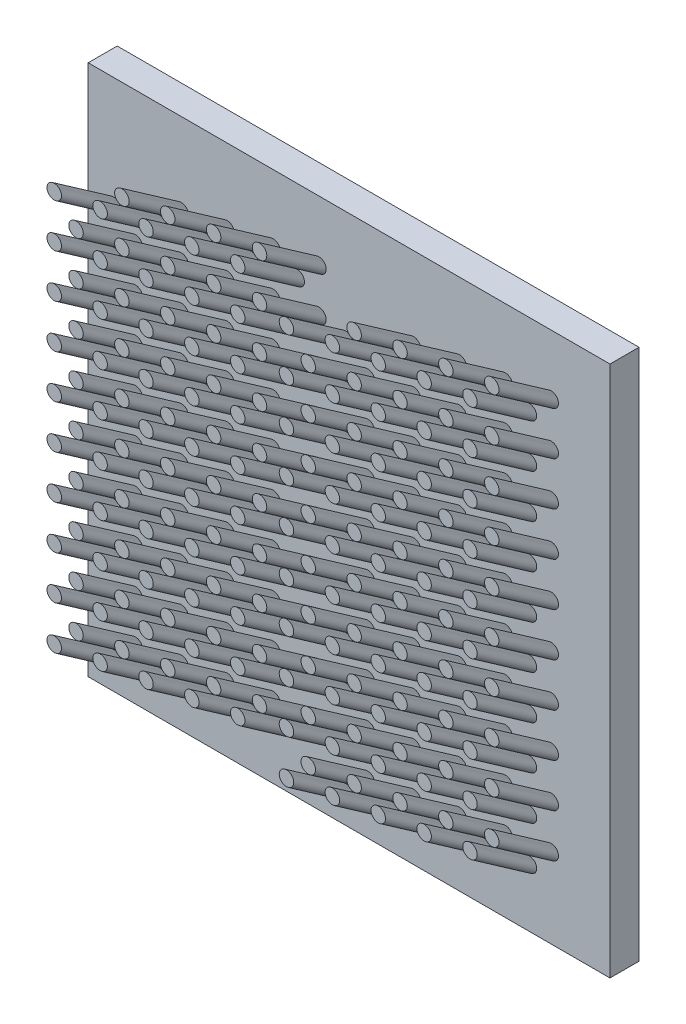
from build123d import *

# Parameters (mm, degrees)
SKETCH1_R       = 0.125
EXTRUDE1_DEPTH  = 1.25
LPATTERN2_COUNT = 2
LPATTERN2_PITCH = 4
EXTRUDE2_START  = -0.5
SKETCH5_W       = 8.986878449
SKETCH5_H       = 9.157970872
EXTRUDE2_DEPTH  = 0.5


with BuildPart() as part:
    # Sketch1 → Extrude1 (new body, along a direction that is not the sketch's normal)
    with BuildSketch(Plane.XY):
        with Locations((3.16060269, 0.500590288)):
            Circle(SKETCH1_R)
        with Locations((3.16060269, 1.250590288)):
            Circle(SKETCH1_R)
        with Locations((3.16060269, 2.000590288)):
            Circle(SKETCH1_R)
        with Locations((3.16060269, 2.750590288)):
            Circle(SKETCH1_R)
        with Locations((3.16060269, 3.500590288)):
            Circle(SKETCH1_R)
        with Locations((3.16060269, 4.250590288)):
            Circle(SKETCH1_R)
        with Locations((3.16060269, 5.000590288)):
            Circle(SKETCH1_R)
        with Locations((3.16060269, 5.750590288)):
            Circle(SKETCH1_R)
        with Locations((3.16060269, 6.500590288)):
            Circle(SKETCH1_R)
        with Locations((3.16060269, 7.250590288)):
            Circle(SKETCH1_R)
        with Locations((3.535546061, 0.875533659)):
            Circle(SKETCH1_R)
        with Locations((3.535546061, 1.625533659)):
            Circle(SKETCH1_R)
        with Locations((3.535546061, 2.375533659)):
            Circle(SKETCH1_R)
        with Locations((3.535546061, 3.125533659)):
            Circle(SKETCH1_R)
        with Locations((3.535546061, 3.875533659)):
            Circle(SKETCH1_R)
        with Locations((3.535546061, 4.625533659)):
            Circle(SKETCH1_R)
        with Locations((3.535546061, 5.375533659)):
            Circle(SKETCH1_R)
        with Locations((3.535546061, 6.125533659)):
            Circle(SKETCH1_R)
        with Locations((3.535546061, 6.875533659)):
            Circle(SKETCH1_R)
        with Locations((3.950753362, 0.62573786)):
            Circle(SKETCH1_R)
        with Locations((3.950753362, 1.37573786)):
            Circle(SKETCH1_R)
        with Locations((3.950753362, 2.12573786)):
            Circle(SKETCH1_R)
        with Locations((3.950753362, 2.87573786)):
            Circle(SKETCH1_R)
        with Locations((3.950753362, 3.62573786)):
            Circle(SKETCH1_R)
        with Locations((3.950753362, 4.37573786)):
            Circle(SKETCH1_R)
        with Locations((3.950753362, 5.12573786)):
            Circle(SKETCH1_R)
        with Locations((3.950753362, 5.87573786)):
            Circle(SKETCH1_R)
        with Locations((3.950753362, 6.62573786)):
            Circle(SKETCH1_R)
        with Locations((3.950753362, 7.37573786)):
            Circle(SKETCH1_R)
        with Locations((4.325696733, 1.000681231)):
            Circle(SKETCH1_R)
        with Locations((4.325696733, 1.750681231)):
            Circle(SKETCH1_R)
        with Locations((4.325696733, 2.500681231)):
            Circle(SKETCH1_R)
        with Locations((4.325696733, 3.250681231)):
            Circle(SKETCH1_R)
        with Locations((4.325696733, 4.000681231)):
            Circle(SKETCH1_R)
        with Locations((4.325696733, 4.750681231)):
            Circle(SKETCH1_R)
        with Locations((4.325696733, 5.500681231)):
            Circle(SKETCH1_R)
        with Locations((4.325696733, 6.250681231)):
            Circle(SKETCH1_R)
        with Locations((4.325696733, 7.000681231)):
            Circle(SKETCH1_R)
        with Locations((4.325696733, 7.750681231)):
            Circle(SKETCH1_R)
        with Locations((4.740904035, 0.750885432)):
            Circle(SKETCH1_R)
        with Locations((4.740904035, 1.500885432)):
            Circle(SKETCH1_R)
        with Locations((4.740904035, 2.250885432)):
            Circle(SKETCH1_R)
        with Locations((4.740904035, 3.000885432)):
            Circle(SKETCH1_R)
        with Locations((4.740904035, 3.750885432)):
            Circle(SKETCH1_R)
        with Locations((4.740904035, 4.500885432)):
            Circle(SKETCH1_R)
        with Locations((4.740904035, 5.250885432)):
            Circle(SKETCH1_R)
        with Locations((4.740904035, 6.000885432)):
            Circle(SKETCH1_R)
        with Locations((4.740904035, 6.750885432)):
            Circle(SKETCH1_R)
        with Locations((4.740904035, 7.500885432)):
            Circle(SKETCH1_R)
        with Locations((5.115847406, 1.125828803)):
            Circle(SKETCH1_R)
        with Locations((5.115847406, 1.875828803)):
            Circle(SKETCH1_R)
        with Locations((5.115847406, 2.625828803)):
            Circle(SKETCH1_R)
        with Locations((5.115847406, 3.375828803)):
            Circle(SKETCH1_R)
        with Locations((5.115847406, 4.125828803)):
            Circle(SKETCH1_R)
        with Locations((5.115847406, 4.875828803)):
            Circle(SKETCH1_R)
        with Locations((5.115847406, 5.625828803)):
            Circle(SKETCH1_R)
        with Locations((5.115847406, 6.375828803)):
            Circle(SKETCH1_R)
        with Locations((5.115847406, 7.125828803)):
            Circle(SKETCH1_R)
        with Locations((5.115847406, 7.875828803)):
            Circle(SKETCH1_R)
        with Locations((5.531054707, 0.876033004)):
            Circle(SKETCH1_R)
        with Locations((5.531054707, 1.626033004)):
            Circle(SKETCH1_R)
        with Locations((5.531054707, 2.376033004)):
            Circle(SKETCH1_R)
        with Locations((5.531054707, 3.126033004)):
            Circle(SKETCH1_R)
        with Locations((5.531054707, 3.876033004)):
            Circle(SKETCH1_R)
        with Locations((5.531054707, 4.626033004)):
            Circle(SKETCH1_R)
        with Locations((5.531054707, 5.376033004)):
            Circle(SKETCH1_R)
        with Locations((5.531054707, 6.126033004)):
            Circle(SKETCH1_R)
        with Locations((5.531054707, 6.876033004)):
            Circle(SKETCH1_R)
        with Locations((5.531054707, 7.626033004)):
            Circle(SKETCH1_R)
        with Locations((5.905998078, 1.250976375)):
            Circle(SKETCH1_R)
        with Locations((5.905998078, 2.000976375)):
            Circle(SKETCH1_R)
        with Locations((5.905998078, 2.750976375)):
            Circle(SKETCH1_R)
        with Locations((5.905998078, 3.500976375)):
            Circle(SKETCH1_R)
        with Locations((5.905998078, 4.250976375)):
            Circle(SKETCH1_R)
        with Locations((5.905998078, 5.000976375)):
            Circle(SKETCH1_R)
        with Locations((5.905998078, 5.750976375)):
            Circle(SKETCH1_R)
        with Locations((5.905998078, 6.500976375)):
            Circle(SKETCH1_R)
        with Locations((5.905998078, 7.250976375)):
            Circle(SKETCH1_R)
        with Locations((5.905998078, 8.000976375)):
            Circle(SKETCH1_R)
        with Locations((6.32120538, 1.001180576)):
            Circle(SKETCH1_R)
        with Locations((6.32120538, 1.751180576)):
            Circle(SKETCH1_R)
        with Locations((6.32120538, 2.501180576)):
            Circle(SKETCH1_R)
        with Locations((6.32120538, 3.251180576)):
            Circle(SKETCH1_R)
        with Locations((6.32120538, 4.001180576)):
            Circle(SKETCH1_R)
        with Locations((6.32120538, 4.751180576)):
            Circle(SKETCH1_R)
        with Locations((6.32120538, 5.501180576)):
            Circle(SKETCH1_R)
        with Locations((6.32120538, 6.251180576)):
            Circle(SKETCH1_R)
        with Locations((6.32120538, 7.001180576)):
            Circle(SKETCH1_R)
        with Locations((6.32120538, 7.751180576)):
            Circle(SKETCH1_R)
        with Locations((6.696148751, 1.376123947)):
            Circle(SKETCH1_R)
        with Locations((6.696148751, 2.126123947)):
            Circle(SKETCH1_R)
        with Locations((6.696148751, 2.876123947)):
            Circle(SKETCH1_R)
        with Locations((6.696148751, 3.626123947)):
            Circle(SKETCH1_R)
        with Locations((6.696148751, 4.376123947)):
            Circle(SKETCH1_R)
        with Locations((6.696148751, 5.126123947)):
            Circle(SKETCH1_R)
        with Locations((6.696148751, 5.876123947)):
            Circle(SKETCH1_R)
        with Locations((6.696148751, 6.626123947)):
            Circle(SKETCH1_R)
        with Locations((6.696148751, 7.376123947)):
            Circle(SKETCH1_R)
        with Locations((6.696148751, 8.126123947)):
            Circle(SKETCH1_R)
    extrude1 = extrude(amount=EXTRUDE1_DEPTH, dir=(0, 0.573576436, 0.819152044))



with BuildPart() as lpattern2_1:
    # LPattern2: Extrude1 ×2
    with Locations(*[(-i * LPATTERN2_PITCH, 0, 0) for i in range(1, LPATTERN2_COUNT)]):
        add(extrude1)


with BuildPart() as part_1:
    add(part.part)

    add(lpattern2_1.part)  # Extrude2 merges LPattern2_1
    # Sketch5 → Extrude2 (add)
    with BuildSketch(Plane.XY.offset(EXTRUDE2_START)):
        with Locations((3.214661322, 4.578985436)):
            Rectangle(SKETCH5_W, SKETCH5_H)
    extrude(amount=EXTRUDE2_DEPTH)


solid = part_1.part
